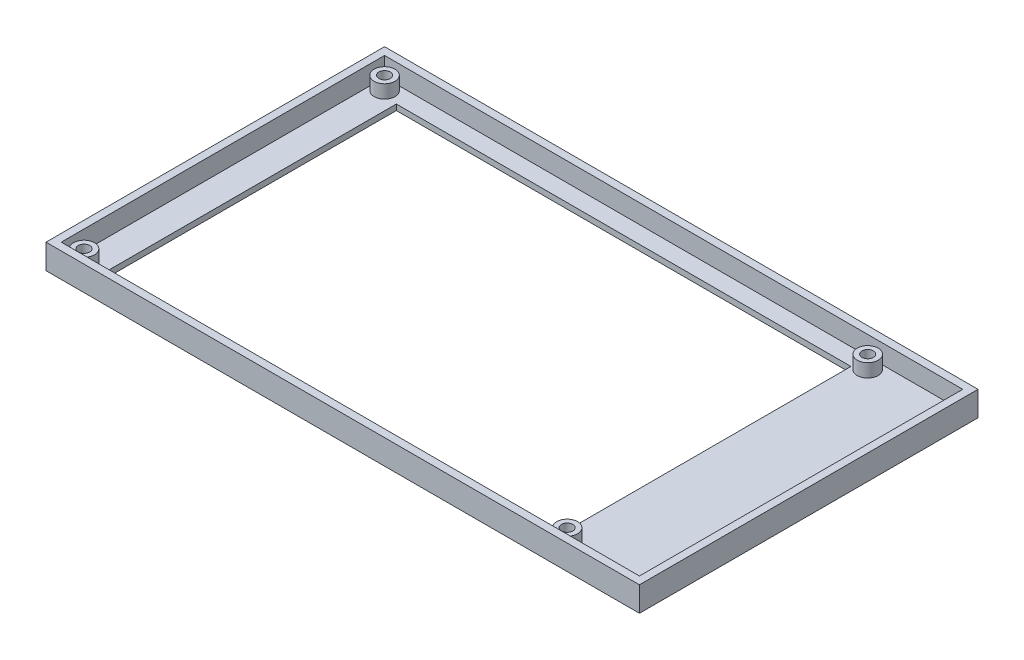
from build123d import *

# Parameters (mm, degrees)
CROQUIS1_W                   = 152
CROQUIS1_H                   = 85
SALIENTE_EXTRUIR1_DEPTH      = 1.5
CROQUIS2_W                   = 156
CROQUIS2_H                   = 89
CROQUIS2_W_2                 = 152
CROQUIS2_H_2                 = 85
SALIENTE_EXTRUIR3_DEPTH      = 5
SALIENTE_EXTRUIR3_DEPTH_BACK = 1.5
CROQUIS3_R                   = 2.75
SALIENTE_EXTRUIR4_DEPTH      = 3.5
CROQUIS4_W                   = 119.5
CROQUIS4_H                   = 78.5
CORTAR_EXTRUIR1_DEPTH        = 1.5
CROQUIS5_R                   = 1.5
CORTAR_EXTRUIR2_DEPTH        = 3


with BuildPart() as part:
    # Croquis1 → Saliente-Extruir1 (new body)
    with BuildSketch(Plane(origin=(0, 0, 0), x_dir=(1, 0, 0), z_dir=(0, 1, 0))):
        with Locations((76, 42.5)):
            Rectangle(CROQUIS1_W, CROQUIS1_H)
    extrude(amount=SALIENTE_EXTRUIR1_DEPTH)

    # Croquis2 → Saliente-Extruir3 (add, two sides)
    with BuildSketch(Plane(origin=(0, 1.5, 0), x_dir=(1, 0, 0), z_dir=(0, 1, 0))) as saliente_extruir3_sk:
        with Locations((76, 42.5)):
            Rectangle(CROQUIS2_W, CROQUIS2_H)
        with Locations((76, 42.5)):
            Rectangle(CROQUIS2_W_2, CROQUIS2_H_2, mode=Mode.SUBTRACT)
    extrude(amount=SALIENTE_EXTRUIR3_DEPTH)
    extrude(saliente_extruir3_sk.sketch, amount=-SALIENTE_EXTRUIR3_DEPTH_BACK)

    # Croquis3 → Saliente-Extruir4 (add)
    with BuildSketch(Plane(origin=(0, 1.5, 0), x_dir=(1, 0, 0), z_dir=(0, 1, 0))):
        with Locations((3, 82)):
            Circle(CROQUIS3_R)
        with Locations((3, 3)):
            Circle(CROQUIS3_R)
        with Locations((130, 82)):
            Circle(CROQUIS3_R)
        with Locations((130, 3)):
            Circle(CROQUIS3_R)
    extrude(amount=SALIENTE_EXTRUIR4_DEPTH)

    # Croquis4 → Cortar-Extruir1 (cut)
    with BuildSketch(Plane.XZ):
        with Locations((67.35, -41.25)):
            Rectangle(CROQUIS4_W, CROQUIS4_H)
    extrude(amount=-CORTAR_EXTRUIR1_DEPTH, mode=Mode.SUBTRACT)

    # Croquis5 → Cortar-Extruir2 (cut)
    with BuildSketch(Plane(origin=(0, 5, 0), x_dir=(1, 0, 0), z_dir=(0, 1, 0))):
        with Locations((130, 3)):
            Circle(CROQUIS5_R)
        with Locations((3, 3)):
            Circle(CROQUIS5_R)
        with Locations((3, 82)):
            Circle(CROQUIS5_R)
        with Locations((130, 82)):
            Circle(CROQUIS5_R)
    extrude(amount=-CORTAR_EXTRUIR2_DEPTH, mode=Mode.SUBTRACT)


solid = part.part
